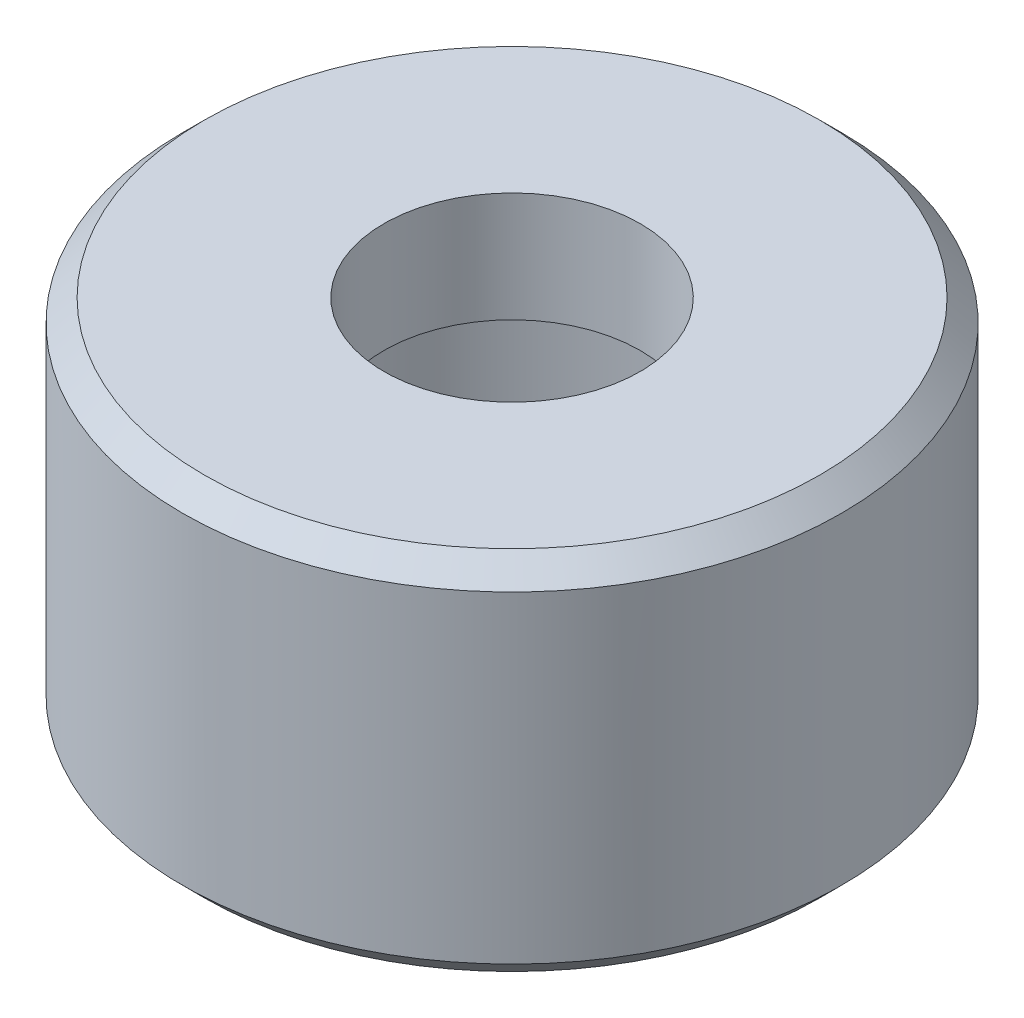
from build123d import *

# Parameters (mm, degrees)
CHAMFER1_SIZE = 0.3


with BuildPart() as part:
    # Sketch2 → Revolve1 (revolve)
    with BuildSketch(Plane(origin=(0, 0, 0), x_dir=(0, 0, -1), z_dir=(1, 0, 0))):
        Polygon((1.75, 5), (1.75, 3.5), (3, 3.5), (3, 0), (4.5, 0), (4.5, 5), align=None)
    revolve(axis=Axis((0, 0, 0), (0, 1, 0)))

    # Chamfer1
    chamfer1_edges = [part.edges().sort_by_distance(p)[0] for p in [
        (0, 5, 4.5),
        (0, 0, 4.5),
    ]]
    chamfer(chamfer1_edges, length=CHAMFER1_SIZE)


solid = part.part
